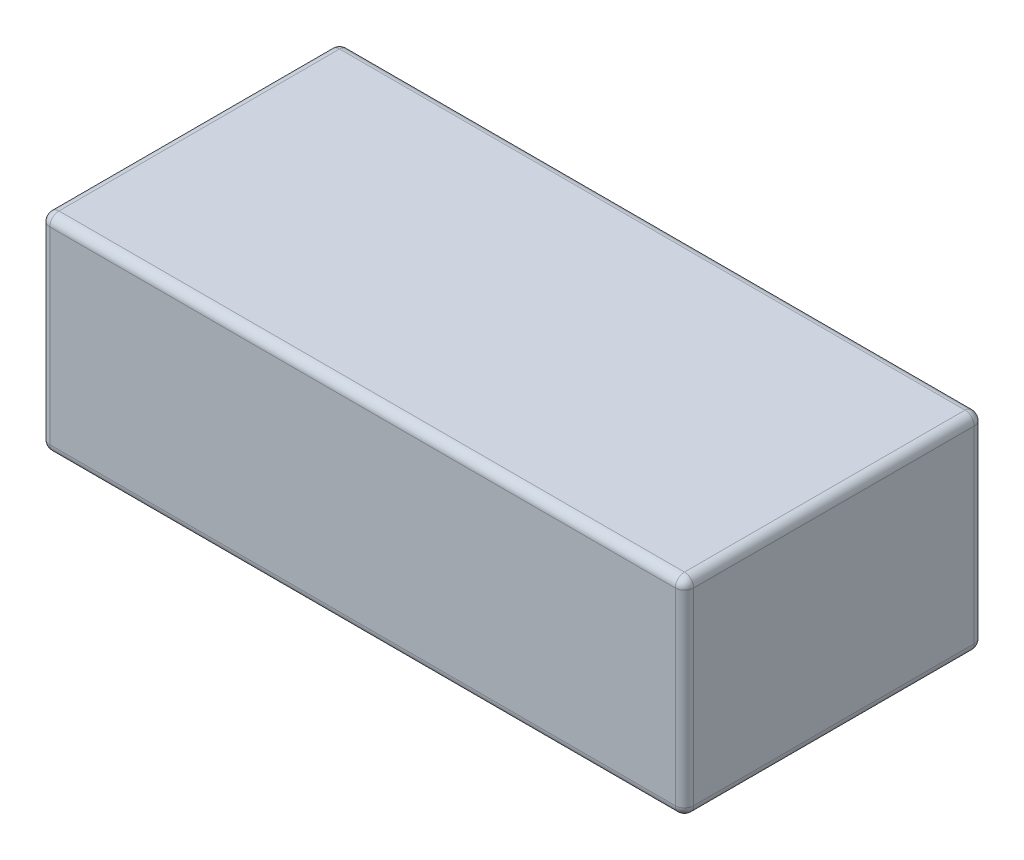
from build123d import *

# Parameters (mm, degrees)
SCHIZZO1_W                   = 140
SCHIZZO1_H                   = 45
ESTRUSIONE_ESTRUSIONE1_DEPTH = 32.5
RACCORDO1_R                  = 2


with BuildPart() as part:
    # Schizzo1 → Estrusione-Estrusione1 (new body, symmetric)
    with BuildSketch(Plane.XY):
        Rectangle(SCHIZZO1_W, SCHIZZO1_H)
    extrude(amount=ESTRUSIONE_ESTRUSIONE1_DEPTH, both=True)

    # Raccordo1
    raccordo1_edges = [part.edges().sort_by_distance(p)[0] for p in [
        (-70, 0, 32.5),
        (0, -22.5, 32.5),
        (70, 0, 32.5),
        (0, -22.5, -32.5),
        (-70, 0, -32.5),
        (0, 22.5, -32.5),
        (70, 0, -32.5),
        (0, 22.5, 32.5),
        (70, -22.5, 0),
        (-70, -22.5, 0),
        (-70, 22.5, 0),
        (70, 22.5, 0),
    ]]
    fillet(raccordo1_edges, radius=RACCORDO1_R)


solid = part.part
